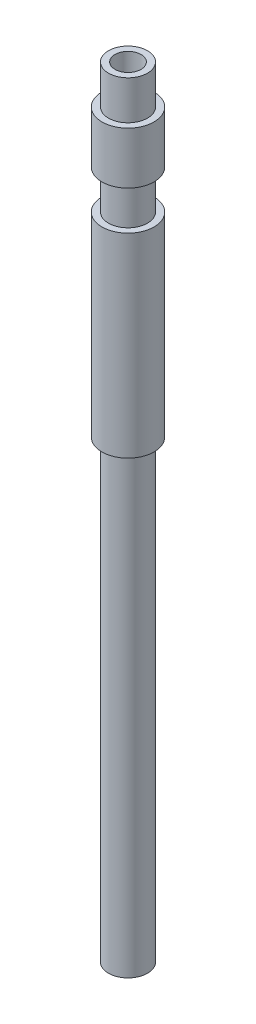
from build123d import *

# Parameters (mm, degrees)
SKETCH_1_R      = 2
SKETCH_1_R_2    = 1
EXTRUDE_1_DEPTH = 60
SKETCH_2_W      = 0.5
SKETCH_2_H      = 3
SKETCH_3_W      = 0.5
SKETCH_3_H      = 35


with BuildPart() as part:
    # Эскиз1 → Бобышка-Вытянуть1 (new body)
    with BuildSketch(Plane(origin=(0, 0, 0), x_dir=(1, 0, 0), z_dir=(0, 1, 0))):
        Circle(SKETCH_1_R)
        Circle(SKETCH_1_R_2, mode=Mode.SUBTRACT)
    extrude(amount=EXTRUDE_1_DEPTH)

    # Эскиз2 → Вырез-Повернуть1 (revolve, cut)
    with BuildSketch(Plane.XY):
        with Locations((1.75, 58.5)):
            Rectangle(SKETCH_2_W, SKETCH_2_H)
        with Locations((1.75, 51.5)):
            Rectangle(SKETCH_2_W, SKETCH_2_H)
    revolve(axis=Axis((0, 60, 0), (0, -1, 0)), mode=Mode.SUBTRACT)

    # Эскиз3 → Вырез-Повернуть2 (revolve, cut)
    with BuildSketch(Plane.XY):
        with Locations((1.75, 17.5)):
            Rectangle(SKETCH_3_W, SKETCH_3_H)
    revolve(axis=Axis((0, 0, 0), (0, 1, 0)), mode=Mode.SUBTRACT)


solid = part.part
